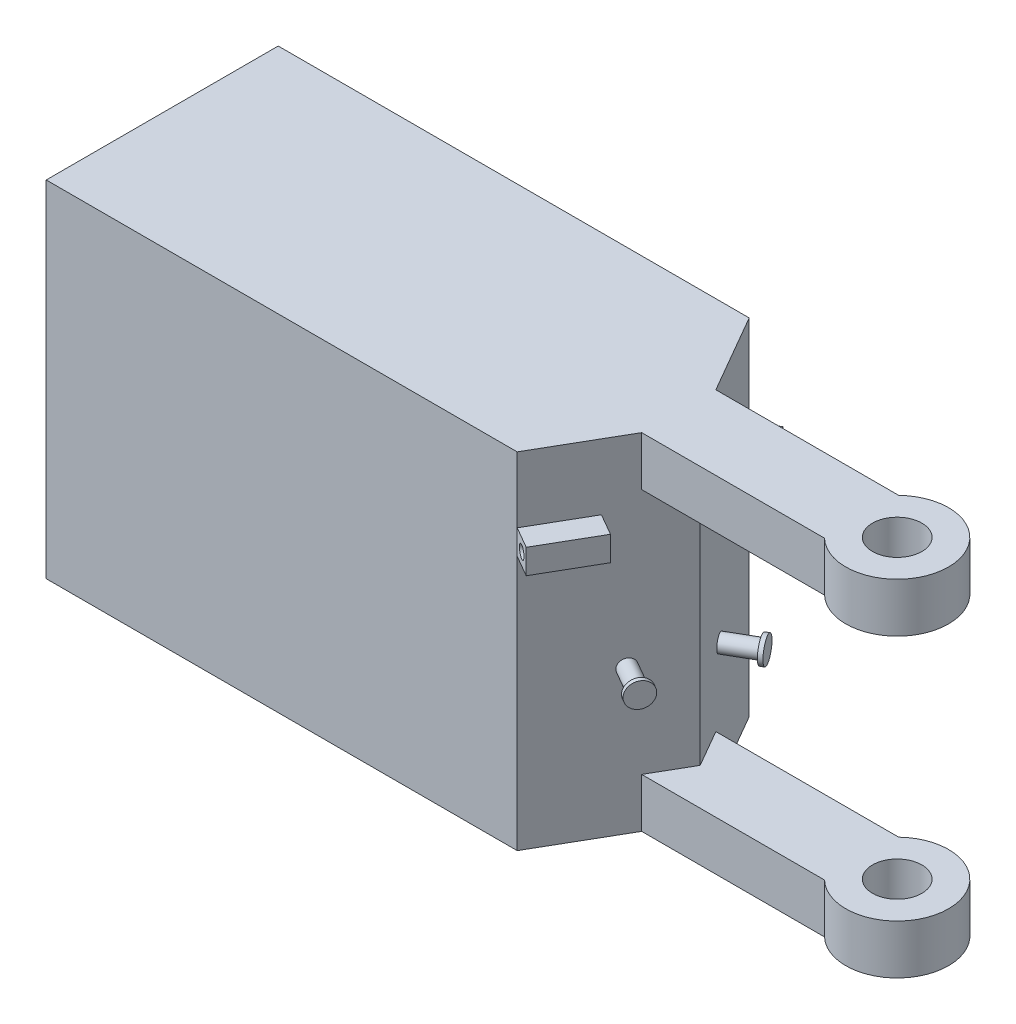
from build123d import *

# Parameters (mm, degrees)
SKETCH4_R            = 6
BOSS_EXTRUDE2_DEPTH  = 12
BOSS_EXTRUDE3_DEPTH  = 30
SKETCH16_R           = 2
BOSS_EXTRUDE9_DEPTH  = 8.5
SKETCH17_R           = 2
BOSS_EXTRUDE10_DEPTH = 8.5
BOSS_EXTRUDE11_DEPTH = 6
SKETCH20_W           = 15
SKETCH20_H           = 6
BOSS_EXTRUDE12_DEPTH = 6
SKETCH22_R           = 3
BOSS_EXTRUDE13_DEPTH = 1
SKETCH23_R           = 3
BOSS_EXTRUDE14_DEPTH = 1
SKETCH27_R           = 1.25
CUT_EXTRUDE4_DEPTH   = 16
SKETCH28_R           = 1.5
CUT_EXTRUDE5_DEPTH   = 17


with BuildPart() as part:
    # Sketch4 → Boss-Extrude2 (new body)
    with BuildSketch(Plane(origin=(0, 0, 0), x_dir=(1, 0, 0), z_dir=(0, 1, 0))):
        with BuildLine():
            Line((0, 28.214565602), (0, -28.214565602))
            Line((0, -28.214565602), (114.556109318, -28.214565602))
            Line((114.556109318, -28.214565602), (125.637290842, -9.021396193))
            Line((125.637290842, -9.021396193), (170.11344646, -9.021396193))
            ThreePointArc((170.11344646, -9.021396193), (191.265868706, 0), (170.11344646, 9.021396193))
            Line((170.11344646, 9.021396193), (125.637290842, 9.021396193))
            Line((125.637290842, 9.021396193), (114.556109318, 28.214565602))
            Line((114.556109318, 28.214565602), (0, 28.214565602))
        make_face()
        with Locations((178.765868706, 0)):
            Circle(SKETCH4_R, mode=Mode.SUBTRACT)
    extrude(amount=BOSS_EXTRUDE2_DEPTH)

    # Sketch6 → Boss-Extrude3 (add)
    with BuildSketch(Plane(origin=(0, 12, 0), x_dir=(1, 0, 0), z_dir=(0, 1, 0))):
        Polygon((0, 0), (0, 28.214565602), (114.556109318, 28.214565602), (125.637290842, 9.021396193), (130.845796363, 0), (114.556109318, -28.214565602), (0, -28.214565602), align=None)
    extrude(amount=BOSS_EXTRUDE3_DEPTH)

    # Mirror5: part across plane


with BuildPart() as part_1:
    add(part.part)
    add(part.part.mirror(Plane(origin=(0, 42, 0), x_dir=(0, 0, 1), z_dir=(0, -1, 0))))

    # Sketch16 → Boss-Extrude9 (add)
    with BuildSketch(Plane(origin=(98.134347272, 0, -56.657891814), x_dir=(-0.5, 0, -0.866025404), z_dir=(0.866025404, 0, -0.5))):
        with Locations((-52.407887359, 29)):
            Circle(SKETCH16_R)
    extrude(amount=BOSS_EXTRUDE9_DEPTH)

    # Sketch17 → Boss-Extrude10 (add)
    with BuildSketch(Plane(origin=(98.134347272, 0, 56.657891814), x_dir=(0.5, 0, -0.866025404), z_dir=(0.866025404, 0, 0.5))):
        with Locations((52.407887359, 35)):
            Circle(SKETCH17_R)
    extrude(amount=BOSS_EXTRUDE10_DEPTH)

    # Sketch18 → Boss-Extrude11 (add)
    with BuildSketch(Plane(origin=(98.134347272, 0, -56.657891814), x_dir=(-0.5, 0, -0.866025404), z_dir=(0.866025404, 0, -0.5))):
        Polygon((-32.843524091, 59), (-32.843524091, 56.190441435), (-45.940020371, 56.190441435), (-45.940020371, 62.190441435), (-32.843524091, 62.190441435), align=None)
    extrude(amount=BOSS_EXTRUDE11_DEPTH)

    # Sketch20 → Boss-Extrude12 (add)
    with BuildSketch(Plane(origin=(98.134347272, 0, 56.657891814), x_dir=(0.5, 0, -0.866025404), z_dir=(0.866025404, 0, 0.5))):
        with Locations((40.343524091, 65)):
            Rectangle(SKETCH20_W, SKETCH20_H)
    extrude(amount=BOSS_EXTRUDE12_DEPTH)

    # Sketch22 → Boss-Extrude13 (add)
    with BuildSketch(Plane(origin=(105.495563204, 0, -60.907891814), x_dir=(-0.5, 0, -0.866025404), z_dir=(0.866025404, 0, -0.5))):
        with Locations((-52.407887359, 29)):
            Circle(SKETCH22_R)
    extrude(amount=-BOSS_EXTRUDE13_DEPTH)

    # Sketch23 → Boss-Extrude14 (add)
    with BuildSketch(Plane(origin=(105.495563204, 0, 60.907891814), x_dir=(0.5, 0, -0.866025404), z_dir=(0.866025404, 0, 0.5))):
        with Locations((52.407887359, 35)):
            Circle(SKETCH23_R)
    extrude(amount=-BOSS_EXTRUDE14_DEPTH)

    # Sketch27 → Cut-Extrude4 (cut)
    with BuildSketch(Plane(origin=(16.421762045, 0, 28.443326212), x_dir=(-0.866025404, 0, 0.5), z_dir=(-0.5, 0, -0.866025404))):
        with Locations((-117.315783629, 59.190441435)):
            Circle(SKETCH27_R)
    extrude(amount=-CUT_EXTRUDE4_DEPTH, mode=Mode.SUBTRACT)

    # Sketch28 → Cut-Extrude5 (cut)
    with BuildSketch(Plane(origin=(23.921762045, 0, -41.433707269), x_dir=(-0.866025404, 0, -0.5), z_dir=(0.5, 0, -0.866025404))):
        with Locations((-116.315783629, 65)):
            Circle(SKETCH28_R)
    extrude(amount=-CUT_EXTRUDE5_DEPTH, mode=Mode.SUBTRACT)


solid = part_1.part
